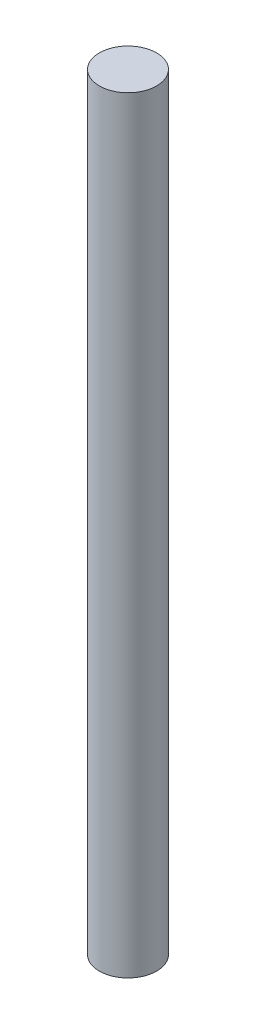
from build123d import *

# Parameters (mm, degrees)
SKETCH1_R           = 1
BOSS_EXTRUDE1_DEPTH = 13.38


with BuildPart() as part:
    # Sketch1 → Boss-Extrude1 (new body, symmetric)
    with BuildSketch(Plane(origin=(0, 0, 0), x_dir=(1, 0, 0), z_dir=(0, 1, 0))):
        Circle(SKETCH1_R)
    extrude(amount=BOSS_EXTRUDE1_DEPTH, both=True)


solid = part.part
